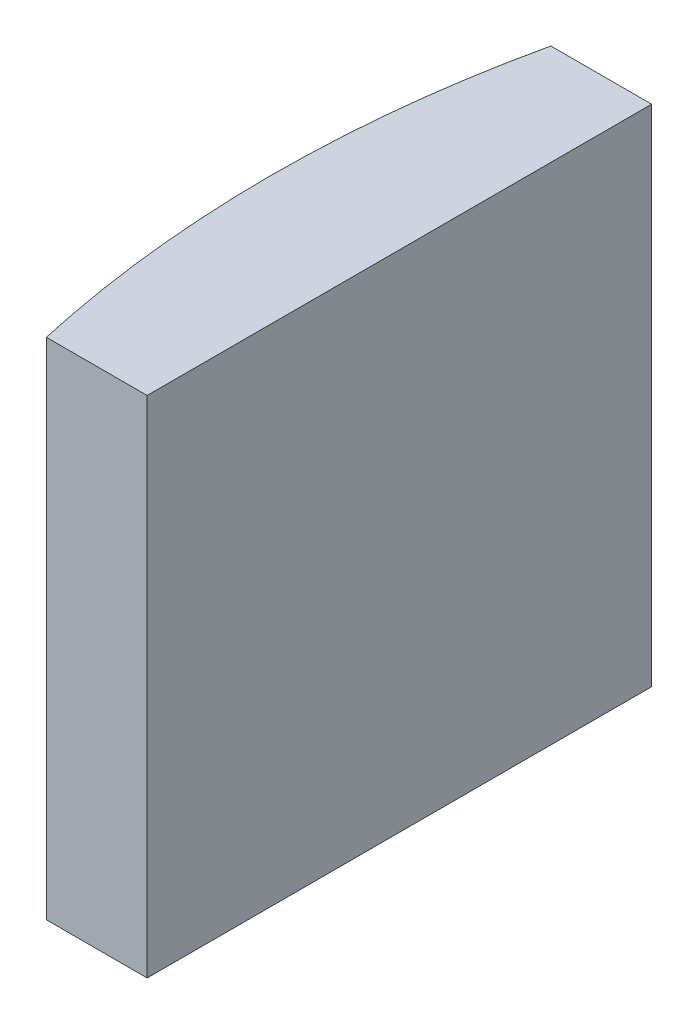
from build123d import *

# Parameters (mm, degrees)
EXTRUDE_1_DEPTH = 10


with BuildPart() as part:
    # 草图1 → 凸台-拉伸1 (new body)
    with BuildSketch(Plane(origin=(0, 0, 0), x_dir=(1, 0, 0), z_dir=(0, 1, 0))):
        with BuildLine():
            Line((-18.012772775, 5), (-16.014795665, 5))
            Line((-16.014795665, 5), (-16.014795665, -5))
            Line((-16.014795665, -5), (-18.012772775, -5))
            ThreePointArc((-18.012772775, -5), (-18.564795665, 0), (-18.012772775, 5))
        make_face()
    extrude(amount=EXTRUDE_1_DEPTH)


solid = part.part
